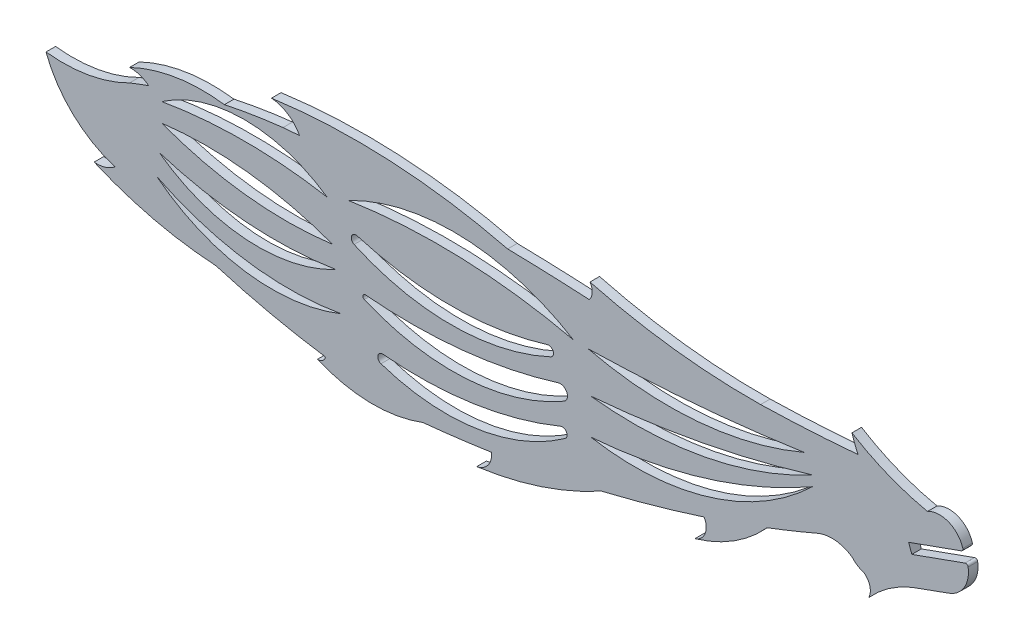
from build123d import *

# Parameters (mm, degrees)
BOSS_EXTRUDE1_DEPTH = 1.524


with BuildPart() as part:
    # Model → Boss-Extrude1 (new body)
    with BuildSketch(Plane.XY):
        with BuildLine():
            Line((134.96008858, 18.319511963), (129.201538518, 16.231235276))
            ThreePointArc((129.201538518, 16.231235276), (125.494314224, 14.202109959), (122.342593367, 11.386525267))
            ThreePointArc((122.342593367, 11.386525267), (122.521547644, 13.015286897), (121.637755911, 14.395069943))
            ThreePointArc((121.637755911, 14.395069943), (120.558535261, 14.894839146), (119.655012959, 15.668230327))
            ThreePointArc((119.655012959, 15.668230327), (116.945656671, 16.627230011), (114.111435919, 16.150276533))
            ThreePointArc((114.111435919, 16.150276533), (110.130348083, 14.492411945), (106.116427247, 12.915701804))
            ThreePointArc((106.116427247, 12.915701804), (100.871077069, 8.483544727), (94.612309809, 5.65767367))
            ThreePointArc((94.612309809, 5.65767367), (96.234412345, 7.167311858), (96.088279041, 9.378390589))
            ThreePointArc((96.088279041, 9.378390589), (87.959563224, 6.916430033), (79.738932416, 4.781365698))
            ThreePointArc((79.738932416, 4.781365698), (70.087015382, 0.573629162), (59.825334355, -1.784855875))
            ThreePointArc((59.825334355, -1.784855875), (61.625546567, -0.674388225), (62.177186804, 1.367570505))
            ThreePointArc((62.177186804, 1.367570505), (56.69945513, 0.613180121), (51.20394484, 0.001611808))
            ThreePointArc((51.20394484, 0.001611808), (42.783253785, -1.45847583), (34.430253575, 0.349086412))
            ThreePointArc((34.430253575, 0.349086412), (35.242407465, 0.582998344), (35.696308866, 1.295937508))
            ThreePointArc((35.696308866, 1.295937508), (26.899874012, 2.912690878), (18.24226034, 5.156991018))
            ThreePointArc((18.24226034, 5.156991018), (8.327270493, 6.613476825), (-1.186477097, 9.762600728))
            ThreePointArc((-1.186477097, 9.762600728), (0.567723509, 9.933888345), (2.129376981, 10.751077214))
            ThreePointArc((2.129376981, 10.751077214), (-4.564424076, 14.67509235), (-8.866303828, 21.132545253))
            ThreePointArc((-8.866303828, 21.132545253), (-2.028267146, 21.342243043), (4.458921798, 23.51459164))
            ThreePointArc((4.458921798, 23.51459164), (5.978589155, 24.100559155), (7.508094135, 24.660346004))
            ThreePointArc((7.508094135, 24.660346004), (6.073839254, 25.435989759), (4.458921798, 25.661271599))
            ThreePointArc((4.458921798, 25.661271599), (11.846812063, 27.976344953), (19.588212991, 28.082169784))
            ThreePointArc((19.588212991, 28.082169784), (24.23969735, 28.951914388), (28.92877134, 29.588583491))
            ThreePointArc((28.92877134, 29.588583491), (30.250891965, 29.696247396), (31.57341018, 29.798912074))
            ThreePointArc((31.57341018, 29.798912074), (29.710039, 31.839896858), (27.095456614, 32.73529062))
            ThreePointArc((27.095456614, 32.73529062), (46.017315853, 33.521760077), (64.749650783, 30.73699449))
            ThreePointArc((64.749650783, 30.73699449), (71.265909378, 30.552300799), (77.77761193, 30.246575893))
            ThreePointArc((77.77761193, 30.246575893), (78.240878226, 31.474299031), (77.877808016, 32.73529062))
            ThreePointArc((77.877808016, 32.73529062), (91.368554355, 30.154894712), (105.083859187, 29.413886469))
            ThreePointArc((105.083859187, 29.413886469), (112.860951548, 29.721873992), (120.624125013, 30.279690879))
            ThreePointArc((120.624125013, 30.279690879), (120.101426826, 31.522338532), (119.655012959, 32.794384617))
            ThreePointArc((119.655012959, 32.794384617), (125.469075261, 29.850060932), (131.706292975, 27.960754811))
            ThreePointArc((131.706292975, 27.960754811), (135.079830026, 28.186864843), (137.333813614, 25.666659301))
            ThreePointArc((137.333813614, 25.666659301), (137.306373673, 25.392750403), (137.099398505, 25.211255734))
            Line((137.099398505, 25.211255734), (128.692975928, 22.19615093))
            Line((128.692975928, 22.19615093), (129.201538518, 20.777960276))
            Line((129.201538518, 20.777960276), (137.683967254, 23.82080051))
            ThreePointArc((137.683967254, 23.82080051), (138.003306934, 23.78963562), (138.181844931, 23.523039923))
            ThreePointArc((138.181844931, 23.523039923), (137.524769068, 20.330730705), (134.96008858, 18.319511963))
        make_face()
        with BuildLine():
            ThreePointArc((113.344379689, 22.19615093), (96.963122218, 12.553503985), (77.990394499, 11.386525267))
            ThreePointArc((77.990394499, 11.386525267), (96.271224533, 14.816426058), (113.344379689, 22.19615093))
        make_face(mode=Mode.SUBTRACT)
        with BuildLine():
            ThreePointArc((113.344379689, 23.82080051), (96.187450512, 17.719248724), (77.990394499, 17.043744891))
            ThreePointArc((77.990394499, 17.043744891), (95.848162694, 19.489217449), (113.344379689, 23.82080051))
        make_face(mode=Mode.SUBTRACT)
        with BuildLine():
            ThreePointArc((112.010038699, 26.273742515), (95.04541072, 22.055495603), (77.613248587, 23.363904105))
            ThreePointArc((77.613248587, 23.363904105), (94.856261251, 24.29140484), (112.010038699, 26.273742515))
        make_face(mode=Mode.SUBTRACT)
        with BuildLine():
            ThreePointArc((73.920433764, 9.144198092), (59.762067232, 3.425519676), (44.552717894, 4.781365698))
            ThreePointArc((44.552717894, 4.781365698), (44.052345371, 5.659967485), (44.86760609, 6.258017419))
            ThreePointArc((44.86760609, 6.258017419), (59.284947166, 6.637177896), (73.189879005, 10.465540071))
            ThreePointArc((73.189879005, 10.465540071), (74.143785851, 10.130315533), (73.920433764, 9.144198092))
        make_face(mode=Mode.SUBTRACT)
        with BuildLine():
            ThreePointArc((73.7171882, 14.19085222), (74.195068041, 15.63804442), (72.809895852, 16.27367986))
            ThreePointArc((72.809895852, 16.27367986), (57.603683966, 13.161162203), (42.082533848, 13.058472776))
            ThreePointArc((42.082533848, 13.058472776), (41.678568271, 12.772614258), (41.897709615, 12.328902245))
            ThreePointArc((41.897709615, 12.328902245), (58.027223609, 9.504074716), (73.7171882, 14.19085222))
        make_face(mode=Mode.SUBTRACT)
        with BuildLine():
            ThreePointArc((71.615953494, 19.263251529), (72.005249, 20.227653753), (71.069824737, 20.682190977))
            ThreePointArc((71.069824737, 20.682190977), (55.942470801, 18.367444511), (40.793050931, 20.533077418))
            ThreePointArc((40.793050931, 20.533077418), (39.862149142, 20.069348511), (40.260924923, 19.10882755))
            ThreePointArc((40.260924923, 19.10882755), (55.955346454, 15.753106638), (71.615953494, 19.263251529))
        make_face(mode=Mode.SUBTRACT)
        with BuildLine():
            ThreePointArc((75.249897816, 23.419828185), (57.358073705, 25.777828917), (39.34157015, 24.737090166))
            ThreePointArc((39.34157015, 24.737090166), (57.468271047, 28.781788902), (75.249897816, 23.419828185))
        make_face(mode=Mode.SUBTRACT)
        with BuildLine():
            ThreePointArc((38.218093055, 8.509361046), (23.165664514, 8.263848957), (8.79939997, 12.763440518))
            ThreePointArc((8.79939997, 12.763440518), (22.937130999, 6.683446576), (38.218093055, 8.509361046))
        make_face(mode=Mode.SUBTRACT)
        with BuildLine():
            ThreePointArc((37.366333435, 14.19085222), (23.1546149, 13.598745989), (9.184351398, 16.27367986))
            ThreePointArc((9.184351398, 16.27367986), (22.976923316, 11.194465897), (37.366333435, 14.19085222))
        make_face(mode=Mode.SUBTRACT)
        with BuildLine():
            ThreePointArc((36.84813704, 17.413649418), (23.030567399, 17.299167045), (9.596276919, 20.533077418))
            ThreePointArc((9.596276919, 20.533077418), (23.40846607, 20.600554903), (36.84813704, 17.413649418))
        make_face(mode=Mode.SUBTRACT)
        with BuildLine():
            ThreePointArc((35.94161169, 23.51459164), (22.768944305, 24.649665002), (9.596276919, 23.51459164))
            ThreePointArc((9.596276919, 23.51459164), (22.768944305, 27.614666916), (35.94161169, 23.51459164))
        make_face(mode=Mode.SUBTRACT)
    extrude(amount=BOSS_EXTRUDE1_DEPTH)


solid = part.part
